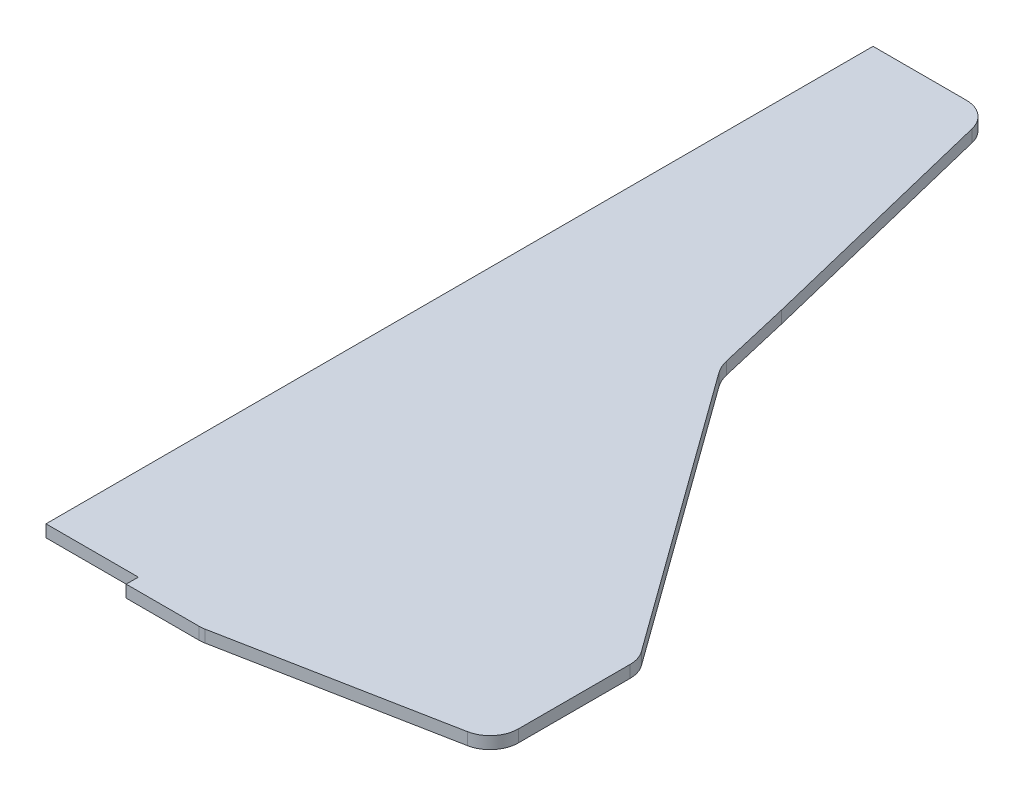
from build123d import *

# Parameters (mm, degrees)
SALIENTE_EXTRUIR1_DEPTH = 3


with BuildPart() as part:
    # Croquis1 → Saliente-Extruir1 (new body)
    with BuildSketch(Plane(origin=(0, 0, 0), x_dir=(1, 0, 0), z_dir=(0, 1, 0))):
        with BuildLine():
            Line((0.226595449, 185.804586765), (-22.78, 185.804586765))
            Line((-22.78, 185.804586765), (-22.78, -18.195413235))
            Line((-22.78, -18.195413235), (0, -18.195413235))
            Line((0, -18.195413235), (0, -21.195413235))
            Line((0, -21.195413235), (18.001591933, -21.195413235))
            ThreePointArc((18.001591933, -21.195413235), (18.666950073, -21.163719955), (19.326283246, -21.068927105))
            Line((19.326283246, -21.068927105), (73.612622199, -10.606644927))
            ThreePointArc((73.612622199, -10.606644927), (77.685747073, -8.18998874), (79.287930885, -3.733131057))
            Line((79.287930885, -3.733131057), (79.287930885, 23.819925262))
            ThreePointArc((79.287930885, 23.819925262), (78.94752374, 25.976270087), (77.959410027, 27.922890572))
            Line((77.959410027, 27.922890572), (27.995644059, 96.987197766))
            ThreePointArc((27.995644059, 96.987197766), (26.997710984, 98.702595555), (26.358179585, 100.581281157))
            Line((26.358179585, 100.581281157), (22.262888034, 118.173345099))
            Line((22.262888034, 118.173345099), (7.026156274, 180.467708103))
            ThreePointArc((7.026156274, 180.467708103), (4.548525031, 184.311030689), (0.226595449, 185.804586765))
        make_face()
    extrude(amount=SALIENTE_EXTRUIR1_DEPTH)


solid = part.part
